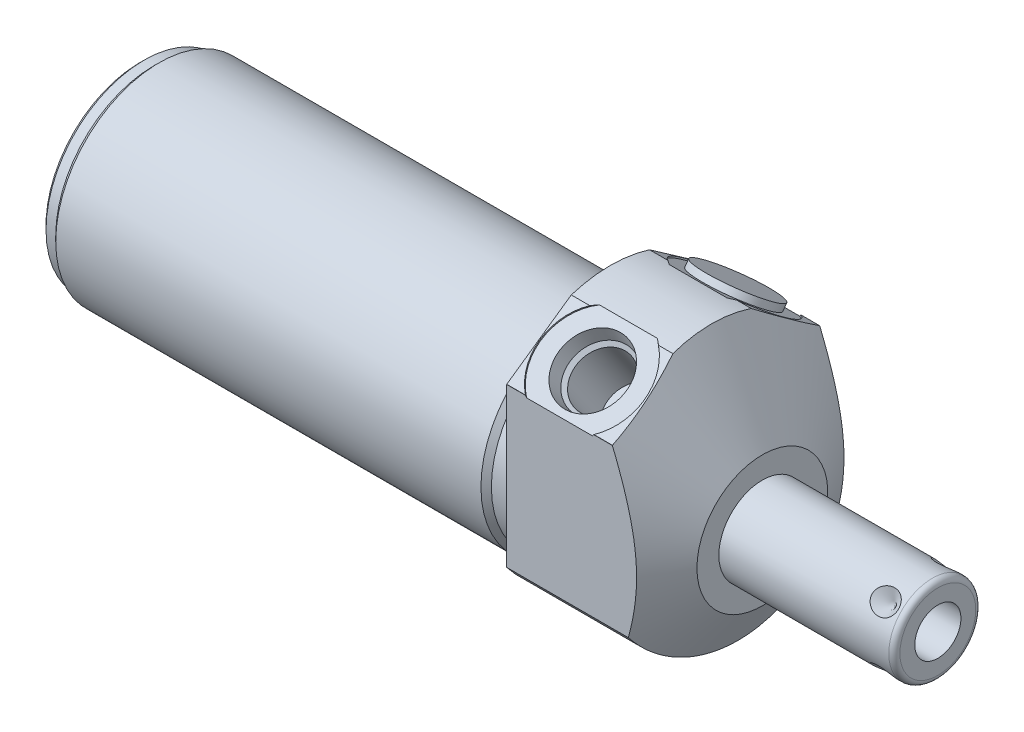
from build123d import *

# Parameters (mm, degrees)
SKETCH1_R           = 23.8125
EXTRUDE1_DEPTH      = 27.7368
EXTRUDE1_DEPTH_BACK = 85.852
CUT_EXTRUDE1_REACH  = 87.852
SKETCH2_R           = 23.8125
SKETCH2_R_2         = 18.8595
CUT_EXTRUDE3_START  = -27.7368
SKETCH4_R           = 28.575
CUT_EXTRUDE3_DEPTH  = 27.7368
SKETCH18_R          = 9.525
CUT_EXTRUDE4_DEPTH  = 0.254
SKETCH19_R          = 9.525
CUT_EXTRUDE5_DEPTH  = 0.254
CHAMFER1_SIZE       = 0.762
CIRPATTERN1_COUNT   = 4
SKETCH20_R          = 6.9469
EXTRUDE2_DEPTH      = 1.27


with BuildPart() as part:
    # Sketch1 → Extrude1 (new body, two sides)
    with BuildSketch(Plane(origin=(0, 0, 0), x_dir=(0, 0, -1), z_dir=(1, 0, 0))) as extrude1_sk:
        Circle(SKETCH1_R)
    extrude(amount=EXTRUDE1_DEPTH)
    extrude(extrude1_sk.sketch, amount=-EXTRUDE1_DEPTH_BACK)

    # Sketch2 → Cut-Extrude1 (cut, up to next)
    with BuildSketch(Plane(origin=(0, 0, 0), x_dir=(0, 0, -1), z_dir=(1, 0, 0)), mode=Mode.PRIVATE) as cut_extrude1_sk1:
        Circle(SKETCH2_R)
        with Locations((0, -4.191)):
            Circle(SKETCH2_R_2, mode=Mode.SUBTRACT)
    cut_extrude1_tool1 = extrude(cut_extrude1_sk1.sketch, amount=-CUT_EXTRUDE1_REACH, mode=Mode.PRIVATE) & part.part
    add(cut_extrude1_tool1.solids().sort_by_distance((0, 0, 23.138981))[0], mode=Mode.SUBTRACT)

    # Sketch4 → Cut-Extrude3 (cut)
    with BuildSketch(Plane.ZY.offset(CUT_EXTRUDE3_START)):
        Circle(SKETCH4_R)
        with BuildLine():
            Line((18.923, -14.455283714), (18.923, 14.465869871))
            Line((18.923, 14.465869871), (0, 27.715897117))
            Line((0, 27.715897117), (-18.923, 14.465869871))
            Line((-18.923, 14.465869871), (-18.923, -14.455283714))
            ThreePointArc((-18.923, -14.455283714), (0, -23.8125), (18.923, -14.455283714))
        make_face(mode=Mode.SUBTRACT)
    extrude(amount=CUT_EXTRUDE3_DEPTH, mode=Mode.SUBTRACT)

    # Sketch6 → Cut-Revolve2 (revolve, cut)
    with BuildSketch(Plane.XY, mode=Mode.PRIVATE) as cut_revolve2_sk:
        Polygon((4.713225965, 47.625), (27.7368, 7.747), (27.7368, 47.625), align=None)
    revolve(cut_revolve2_sk.sketch.rotate(Axis((3.612847264, -4.191, 0), (1, 0, 0)), 270), axis=Axis((3.612847264, -4.191, 0), (1, 0, 0)), mode=Mode.SUBTRACT)  # turned: the seam where the file's is

    # S2D0002 → Cut-Revolve3 (revolve, cut)
    with BuildSketch(Plane(origin=(9.652, 18.394824642, 12.869035589), x_dir=(0, 0.573576436, -0.819152044), z_dir=(1, 0, 0))):
        Polygon((0, 0), (6.1849, 0), (5.642306865, -2.5527), (4.9784, -3.216606865), (4.9784, -13.462), (0, -13.462), align=None)
    revolve(axis=Axis((9.652, 6.816028581, 4.761475303), (0, 0.819152044, 0.573576436)), mode=Mode.SUBTRACT)

    # Sketch8 → Cut-Revolve4 (revolve, cut)
    with BuildSketch(Plane(origin=(9.652, 18.394824642, -12.869035589), x_dir=(0, -0.573576436, -0.819152044), z_dir=(1, 0, 0))):
        Polygon((0, 0), (6.1849, 0), (5.642306865, -2.5527), (4.9784, -3.216606865), (4.9784, -13.462), (0, -13.462), align=None)
    revolve(axis=Axis((9.652, 6.816028581, -4.761475303), (0, 0.819152044, -0.573576436)), mode=Mode.SUBTRACT)

    # Sketch18 → Cut-Extrude4 (cut)
    with BuildSketch(Plane(origin=(0, 18.59764611, 13.022211999), x_dir=(1, 0, 0), z_dir=(0, 0.819152044, 0.573576436))):
        with Locations((9.652, 0.009141155)):
            Circle(SKETCH18_R)
    extrude(amount=-CUT_EXTRUDE4_DEPTH, mode=Mode.SUBTRACT)

    # Sketch19 → Cut-Extrude5 (cut)
    with BuildSketch(Plane(origin=(0, 18.59764611, -13.022211999), x_dir=(1, 0, 0), z_dir=(0, 0.819152044, -0.573576436))):
        with Locations((9.652, -0.009141155)):
            Circle(SKETCH19_R)
    extrude(amount=-CUT_EXTRUDE5_DEPTH, mode=Mode.SUBTRACT)

    # Sketch10 → Cut-Revolve6 (revolve, cut)
    with BuildSketch(Plane.XY, mode=Mode.PRIVATE) as cut_revolve6_sk:
        Polygon((0, 14.6685), (0, 13.716), (-3.81, 13.716), (-4.7625, 14.6685), align=None)
    revolve(cut_revolve6_sk.sketch.rotate(Axis((-5.000625, -4.191, 0), (1, 0, 0)), 90), axis=Axis((-5.000625, -4.191, 0), (1, 0, 0)), mode=Mode.SUBTRACT)  # turned: the seam where the file's is

    # Sketch12 → Cut-Revolve8 (revolve, cut)
    with BuildSketch(Plane.XY, mode=Mode.PRIVATE) as cut_revolve8_sk:
        Polygon((-85.852, 14.6685), (-85.852, 13.716), (-83.312, 13.716), (-82.3595, 14.6685), align=None)
    revolve(cut_revolve8_sk.sketch.rotate(Axis((-63.674625, -4.191, 0), (1, 0, 0)), 90), axis=Axis((-63.674625, -4.191, 0), (1, 0, 0)), mode=Mode.SUBTRACT)  # turned: the seam where the file's is

    # Chamfer1
    chamfer1_edges = [part.edges().sort_by_distance(p)[0] for p in [
        (-85.852, -4.191, -17.907),
    ]]
    chamfer(chamfer1_edges, length=CHAMFER1_SIZE)

    # Sketch13 → Revolve1 (revolve)
    with BuildSketch(Plane(origin=(0, 0, 0), x_dir=(0, -1, 0), z_dir=(0, 0, 1)), mode=Mode.PRIVATE) as revolve1_sk:
        with BuildLine():
            Line((4.191, 27.7368), (4.191, 59.7662))
            Line((4.191, 59.7662), (11.1125, 59.7662))
            ThreePointArc((11.1125, 59.7662), (11.83092049, 59.46862049), (12.1285, 58.7502))
            Line((12.1285, 58.7502), (12.1285, 27.7368))
            Line((12.1285, 27.7368), (4.191, 27.7368))
        make_face()
    revolve(revolve1_sk.sketch.rotate(Axis((26.44521, -4.191, 0), (1, 0, 0)), 270), axis=Axis((26.44521, -4.191, 0), (1, 0, 0)))  # turned: the seam where the file's is

    # S2D0001 → Cut-Revolve9 (revolve, cut)
    with BuildSketch(Plane(origin=(54.6354, -8.4074, 0), x_dir=(0, -1, 0), z_dir=(0, 0, 1)), mode=Mode.PRIVATE) as cut_revolve9_sk:
        Polygon((0, 5.1308), (0, -10.1092), (-4.2164, -12.642668714), (-4.2164, 5.1308), align=None)
    revolve(cut_revolve9_sk.sketch.rotate(Axis((35.97325785, -4.191, 0), (1, 0, 0)), 270), axis=Axis((35.97325785, -4.191, 0), (1, 0, 0)), mode=Mode.SUBTRACT)  # turned: the seam where the file's is

    # Sketch16 → Cut-Revolve10 (revolve, cut)
    with BuildSketch(Plane(origin=(50.673, 1.421660076, -5.612660076), x_dir=(-1, 0, 0), z_dir=(0, -0.707106781, -0.707106781)), mode=Mode.PRIVATE) as cut_revolve10_sk:
        Polygon((-5.1308, 0), (-2.7178, 0), (-5.1308, -2.413), align=None)
    cut_revolve10 = revolve(cut_revolve10_sk.sketch.rotate(Axis((55.8038, -2.1640922, -2.0269078), (0, 0.707106781, -0.707106781)), 90), axis=Axis((55.8038, -2.1640922, -2.0269078), (0, 0.707106781, -0.707106781)), mode=Mode.SUBTRACT)  # turned: the seam where the file's is

    # CirPattern1: Cut-Revolve10 ×4 about axis
    cirpattern1_axis = Axis((26.44521, -4.191, 0), (-1, 0, 0))
    for i in range(1, CIRPATTERN1_COUNT):
        add(cut_revolve10.rotate(cirpattern1_axis, i * 360 / CIRPATTERN1_COUNT), mode=Mode.SUBTRACT)

    # Sketch20 → Extrude2 (add)
    with BuildSketch(Plane(origin=(0, 18.389581491, -12.876523585), x_dir=(1, 0, 0), z_dir=(0, 0.819152044, -0.573576436))):
        with Locations(Location((9.652, -0.009141155, 0), (0, 0, 270))):  # turned: the seam where the file's is
            Circle(SKETCH20_R)
    extrude(amount=EXTRUDE2_DEPTH)

    # Sketch21 → Cut-Revolve11 (revolve, cut)
    with BuildSketch(Plane.XY, mode=Mode.PRIVATE) as cut_revolve11_sk:
        Polygon((-71.882, -4.191), (-85.852, -4.191), (-85.852, -10.3759), (-83.2866, -9.830607397), (-82.625392603, -9.1694), (-71.882, -9.1694), align=None)
    revolve(cut_revolve11_sk.sketch.rotate(Axis((-37.427759391, -4.191, 0), (-1, 0, 0)), 90), axis=Axis((-37.427759391, -4.191, 0), (-1, 0, 0)), mode=Mode.SUBTRACT)  # turned: the seam where the file's is


solid = part.part
